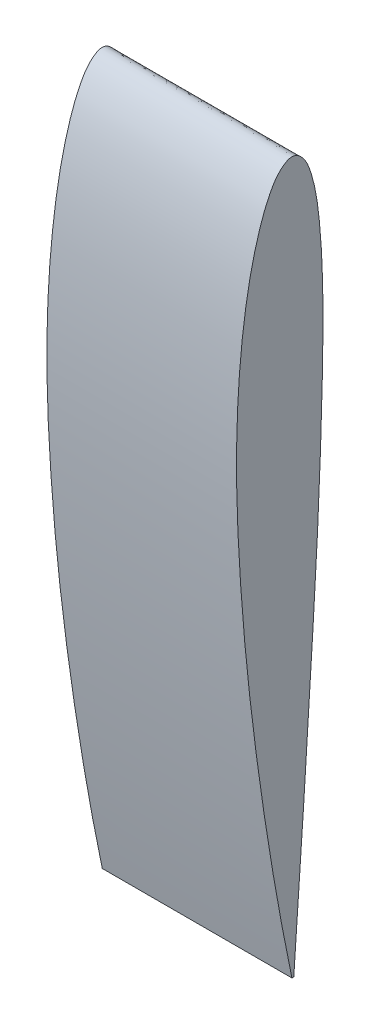
from build123d import *

# Parameters (mm, degrees)
BOSS_EXTRUDE1_DEPTH   = 80
BODY_MOVE_COPY1_ANGLE = 120


with BuildPart() as part:
    # Sketch1 → Boss-Extrude1 (new body)
    with BuildSketch(Plane.XY):
        with BuildLine():
            Line((269.75606318, 0.39), (269.75606318, -0.39))
            add(Edge.make_bspline(
                [(269.75606318, 0.39), (264.758836378, 1.414000082), (254.777507596, 3.45931079), (234.797708888, 7.205579334), (209.809502227, 11.35644797), (179.803810027, 15.652495779), (149.803067524, 19.235240906), (119.789318532, 21.858580513), (89.782404697, 23.635097209), (64.746727737, 23.935808407), (44.737918653, 23.107465721), (29.719041415, 21.893704318), (14.681203014, 19.97163417), (2.165982385, 17.604753461), (-7.811397109, 14.926973956), (-15.375659845, 12.492476274), (-21.78446685, 9.655920822), (-27.312645833, 6.216911108), (-32.133405509, 0.269631354), (-27.125920641, -4.957920198), (-21.701145045, -7.342160266), (-15.320533432, -9.153243486), (-7.781174347, -10.451795047), (2.236136575, -11.559964158), (14.740172541, -12.412907572), (29.754296801, -12.754877712), (44.757705477, -12.707223024), (64.759558695, -12.26571363), (89.764209215, -11.471242967), (119.766079926, -10.088623246), (149.759251014, -8.291561108), (179.757509222, -6.423658887), (209.760896614, -4.532938454), (234.755492949, -2.791593222), (254.757335305, -1.448461772), (264.756258336, -0.742836743), (269.75606318, -0.39)],
                knots=[0, 0, 0, 0, 0.02501249, 0.049959286, 0.099672925, 0.14920632, 0.198581097, 0.24780517, 0.296916575, 0.345952722, 0.370491626, 0.395091204, 0.419814796, 0.444798575, 0.457489819, 0.470406405, 0.483879409, 0.49126412, 0.503458853, 0.513609129, 0.520450991, 0.533235388, 0.545691039, 0.558031884, 0.582609167, 0.607134742, 0.63165208, 0.656174272, 0.705233949, 0.754320379, 0.803437364, 0.852566096, 0.901700994, 0.950848809, 0.975422717, 1, 1, 1, 1], degree=3))
        make_face()
    extrude(amount=BOSS_EXTRUDE1_DEPTH)


with BuildPart() as part_1:
    # Body-Move/Copy1: moved
    add(part.part.rotate(Axis((0, 0, 0), (0.577350269, -0.577350269, -0.577350269)), BODY_MOVE_COPY1_ANGLE))


solid = part_1.part
